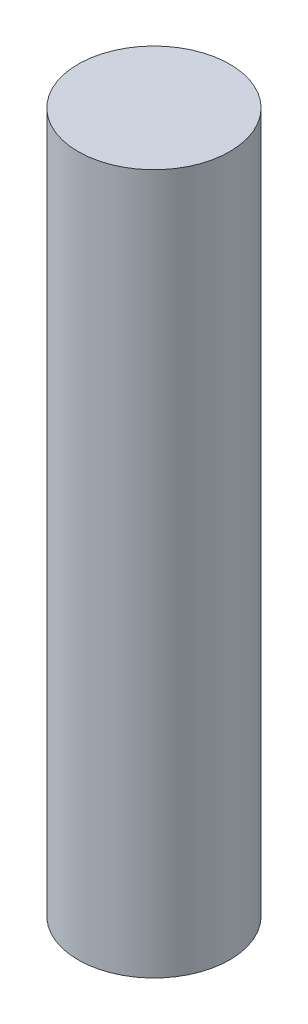
from build123d import *

# Parameters (mm, degrees)
SKETCH1_R           = 2.75
BOSS_EXTRUDE1_DEPTH = 25.4


with BuildPart() as part:
    # Sketch1 → Boss-Extrude1 (new body)
    with BuildSketch(Plane(origin=(0, 0, 0), x_dir=(1, 0, 0), z_dir=(0, 1, 0))):
        Circle(SKETCH1_R)
    extrude(amount=BOSS_EXTRUDE1_DEPTH)


solid = part.part
